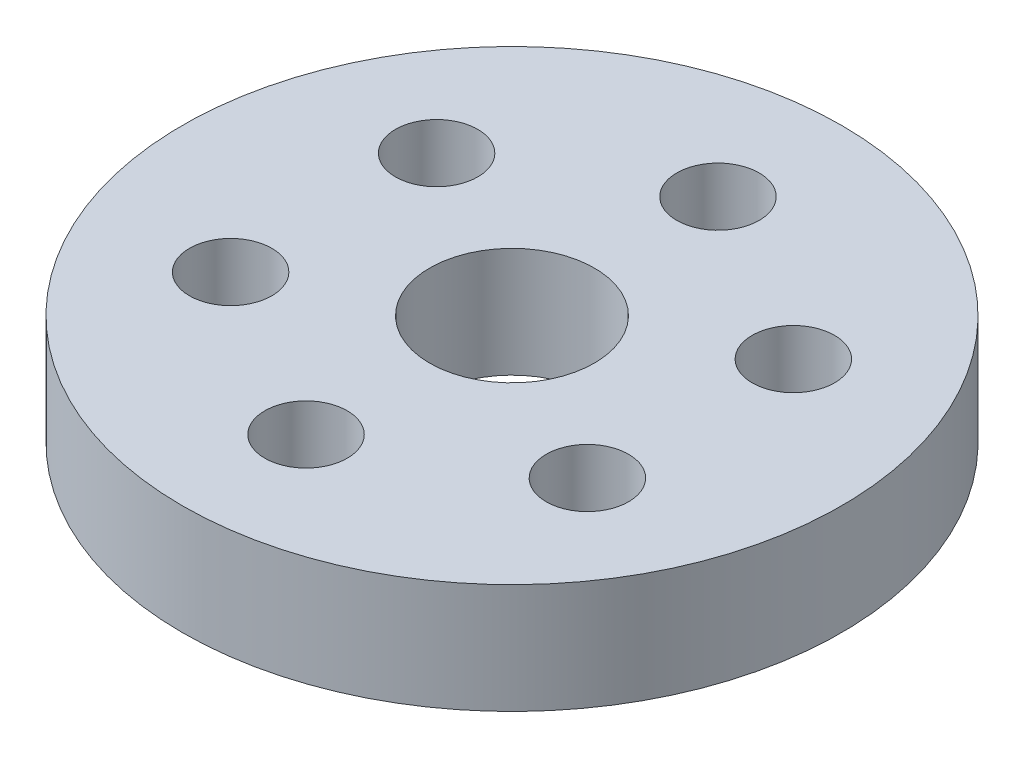
from build123d import *

# Parameters (mm, degrees)
SKETCH1_R               = 12.7
SKETCH1_R_2             = 3.175
BOSS_EXTRUDE1_DEPTH     = 2.116666667
SKETCH2_R               = 1.5875
CUT_EXTRUDE1_DEPTH      = 3.116666667
CUT_EXTRUDE1_DEPTH_BACK = 3.116666667


with BuildPart() as part:
    # Sketch1 → Boss-Extrude1 (new body, symmetric)
    with BuildSketch(Plane(origin=(0, 0, 0), x_dir=(1, 0, 0), z_dir=(0, 1, 0))):
        Circle(SKETCH1_R)
        Circle(SKETCH1_R_2, mode=Mode.SUBTRACT)
    extrude(amount=BOSS_EXTRUDE1_DEPTH, both=True)

    # Sketch2 → Cut-Extrude1 (cut, two sides)
    with BuildSketch(Plane(origin=(0, 0, 0), x_dir=(1, 0, 0), z_dir=(0, 1, 0))) as cut_extrude1_sk:
        with Locations((0, 7.9375)):
            Circle(SKETCH2_R)
        with Locations((6.874076643, 3.96875)):
            Circle(SKETCH2_R)
        with Locations((6.874076643, -3.96875)):
            Circle(SKETCH2_R)
        with Locations((0, -7.9375)):
            Circle(SKETCH2_R)
        with Locations((-6.874076643, -3.96875)):
            Circle(SKETCH2_R)
        with Locations((-6.874076643, 3.96875)):
            Circle(SKETCH2_R)
    extrude(amount=CUT_EXTRUDE1_DEPTH, mode=Mode.SUBTRACT)
    extrude(cut_extrude1_sk.sketch, amount=-CUT_EXTRUDE1_DEPTH_BACK, mode=Mode.SUBTRACT)


solid = part.part
